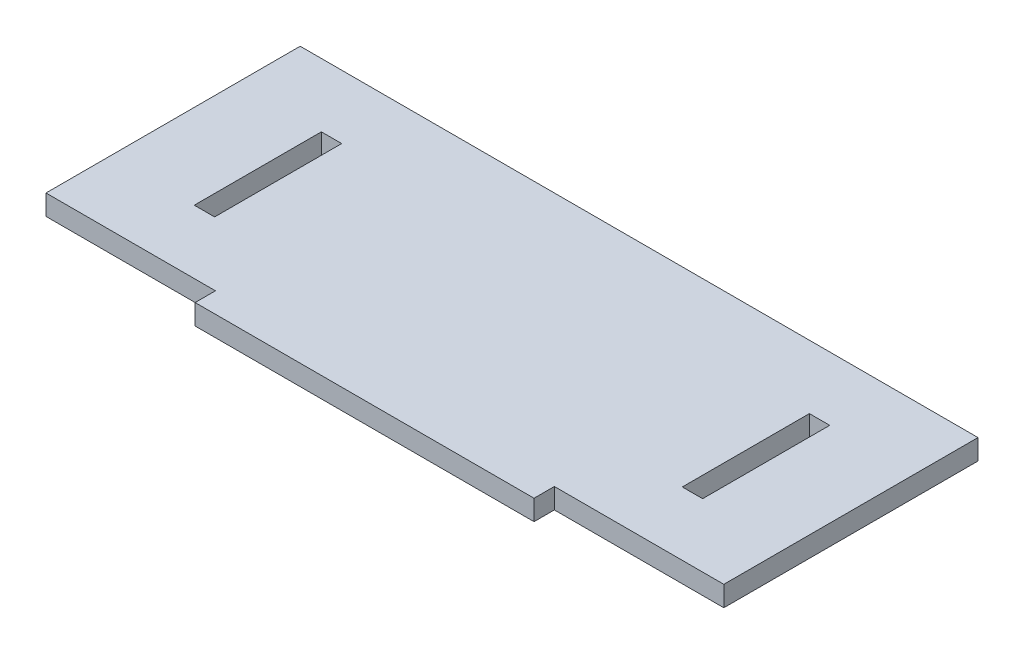
from build123d import *

# Parameters (mm, degrees)
SKETCH1_W           = 200
SKETCH1_H           = 12
BOSS_EXTRUDE1_DEPTH = 12
SKETCH3_W           = 12
SKETCH3_H           = 75
CUT_EXTRUDE1_DEPTH  = 12


with BuildPart() as part:
    # Sketch1 → Boss-Extrude1 (new body)
    with BuildSketch(Plane(origin=(0, 0, 0), x_dir=(1, 0, 0), z_dir=(0, 1, 0))):
        Polygon((200, 75), (-200, 75), (-200, -75), (-100, -75), (-100, -63), (100, -63), (100, -75), (200, -75), align=None)
        with Locations((0, -81)):
            Rectangle(SKETCH1_W, SKETCH1_H)
        with Locations((0, -69)):
            Rectangle(SKETCH1_W, SKETCH1_H)
    extrude(amount=BOSS_EXTRUDE1_DEPTH)

    # Sketch3 → Cut-Extrude1 (cut)
    with BuildSketch(Plane(origin=(0, 12, 0), x_dir=(1, 0, 0), z_dir=(0, 1, 0))):
        with Locations((-144, 0)):
            Rectangle(SKETCH3_W, SKETCH3_H)
    cut_extrude1 = extrude(amount=-CUT_EXTRUDE1_DEPTH, mode=Mode.SUBTRACT)

    # Mirror1: Cut-Extrude1 across plane
    add(cut_extrude1.mirror(Plane(origin=(0, 0, 0), x_dir=(0, 0, 1), z_dir=(1, 0, 0))), mode=Mode.SUBTRACT)


solid = part.part
